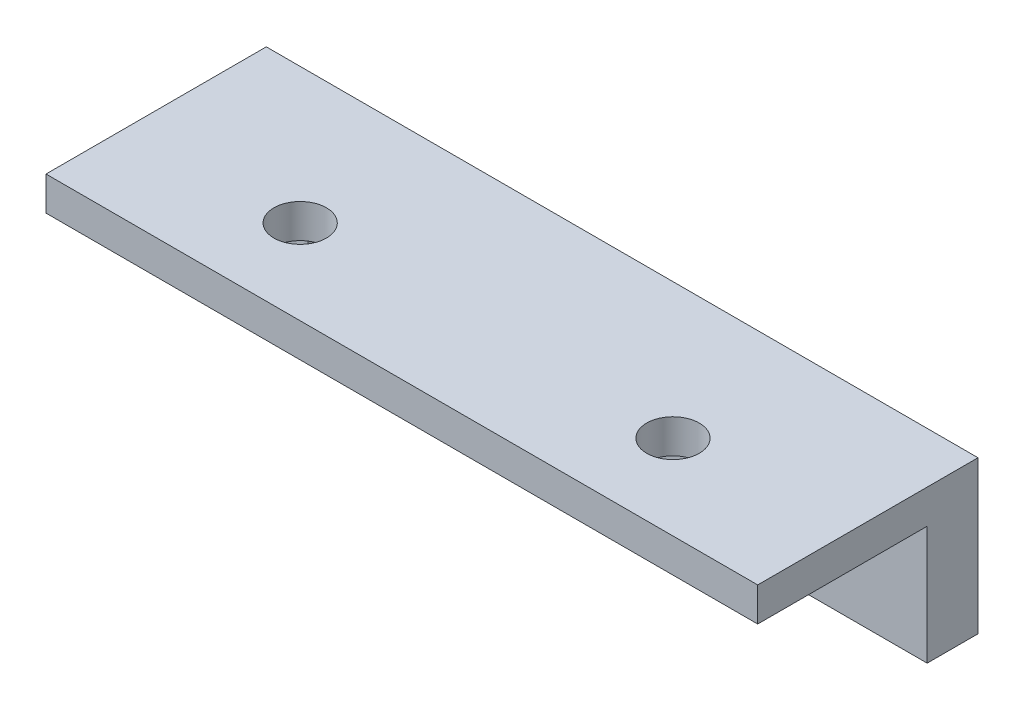
from build123d import *

# Parameters (mm, degrees)
SKETCH_1_W          = 42
SKETCH_1_H          = 7
SKETCH_1_R          = 1.55
EXTRUDE_5_DEPTH     = 3
SKETCH_1_6_W        = 42
SKETCH_1_6_H        = 2
EXTRUDE_6_DEPTH     = 13
SKETCH_4_R          = 1.55
CUT_EXTRUDE_1_DEPTH = 13


with BuildPart() as part:
    # 草图1 → 凸台-拉伸5 (new body)
    with BuildSketch(Plane.XY):
        with Locations((26, 8.5)):
            Rectangle(SKETCH_1_W, SKETCH_1_H)
        with Locations((12, 8.4)):
            Circle(SKETCH_1_R, mode=Mode.SUBTRACT)
        with Locations((40, 8.4)):
            Circle(SKETCH_1_R, mode=Mode.SUBTRACT)
    extrude(amount=EXTRUDE_5_DEPTH)

    # 草图1<6> → 凸台-拉伸6 (add)
    with BuildSketch(Plane.XY):
        with Locations((26, 13)):
            Rectangle(SKETCH_1_6_W, SKETCH_1_6_H)
    extrude(amount=EXTRUDE_6_DEPTH)

    # 草图4 → 切除-拉伸1 (cut)
    with BuildSketch(Plane(origin=(0, 14, 0), x_dir=(1, 0, 0), z_dir=(0, 1, 0))):
        with Locations((15, -8)):
            Circle(SKETCH_4_R)
        with Locations((37, -8)):
            Circle(SKETCH_4_R)
    extrude(amount=-CUT_EXTRUDE_1_DEPTH, mode=Mode.SUBTRACT)


solid = part.part
